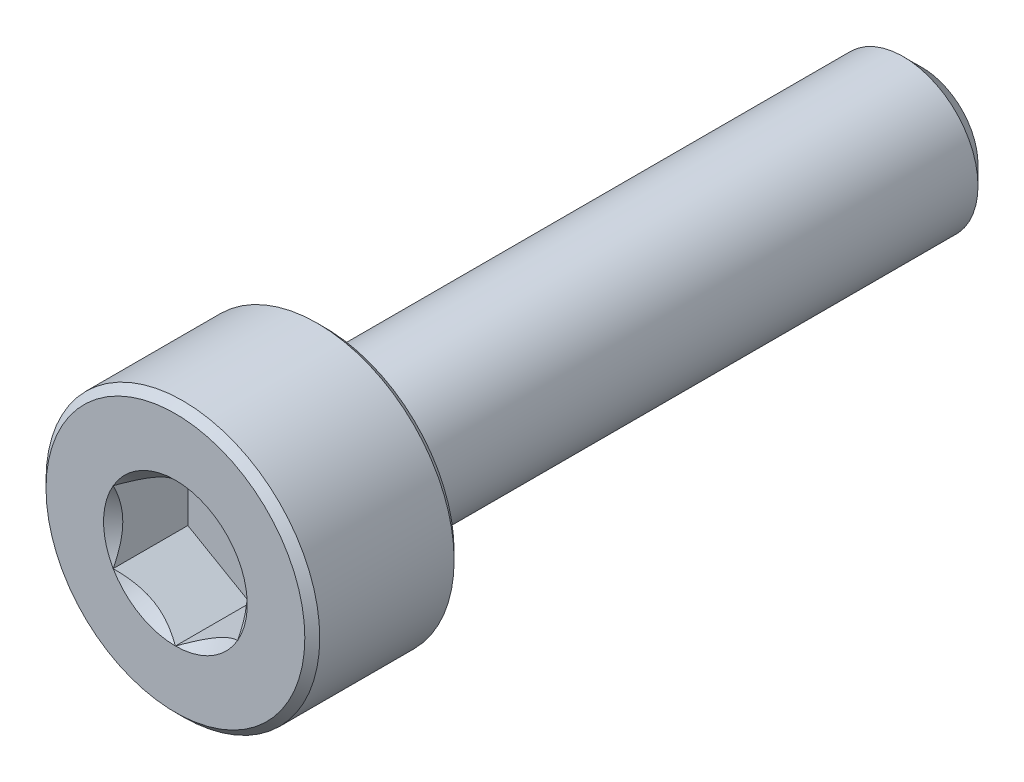
from build123d import *

# Parameters (mm, degrees)
CUT_EXTRUDE1_DEPTH = 1.5
CHAMFER1_SIZE      = 0.15


with BuildPart() as part:
    # Sketch2 → Revolve1 (revolve)
    with BuildSketch(Plane(origin=(0, 0, 0), x_dir=(0, 0, -1), z_dir=(1, 0, 0)), mode=Mode.PRIVATE) as revolve1_sk:
        Polygon((-7.5, 0), (-7.5, 2.75), (-4.5, 2.75), (-4.5, 1.5), (7.125, 1.5), (7.5, 1.125), (7.5, 0), align=None)
    revolve(revolve1_sk.sketch.rotate(Axis((0, 0, 7.5), (0, 0, -1)), 90), axis=Axis((0, 0, 7.5), (0, 0, -1)))

    # Sketch3 → Cut-Extrude1 (cut)
    with BuildSketch(Plane.XY.offset(7.5)):
        Polygon((0, 1.443375673), (-1.25, 0.721687836), (-1.25, -0.721687836), (0, -1.443375673), (1.25, -0.721687836), (1.25, 0.721687836), align=None)
    extrude(amount=-CUT_EXTRUDE1_DEPTH, mode=Mode.SUBTRACT)

    # Cut-Extrude2 cone 1 section (through the dimple's axis) → Cut-Extrude2 (revolve, cut)
    with BuildSketch(Plane(origin=(0, 0, 7.5), x_dir=(0, -1, 0), z_dir=(1, 0, 0))):
        Polygon((0, 0), (1.443375673, 0), (0, 1.443375673), align=None)
    revolve(axis=Axis((0, 0, 7.5), (0, 0, -1)), mode=Mode.SUBTRACT)

    # Chamfer1
    chamfer1_edges = [part.edges().sort_by_distance(p)[0] for p in [
        (-2.75, 0, 4.5),
        (-2.75, 0, 7.5),
    ]]
    chamfer(chamfer1_edges, length=CHAMFER1_SIZE)


solid = part.part
